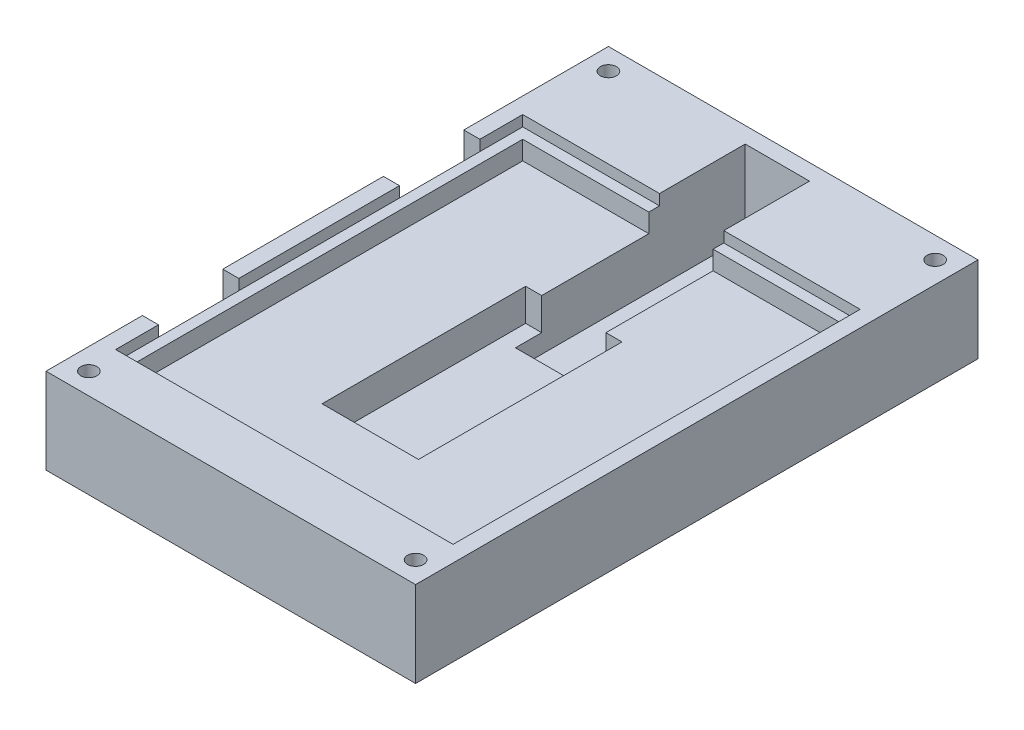
from build123d import *

# Parameters (mm, degrees)
SKETCH1_W           = 69
SKETCH1_H           = 105
BOSS_EXTRUDE1_DEPTH = 16
SKETCH2_W           = 63
SKETCH2_H           = 76
CUT_EXTRUDE1_DEPTH  = 2
SKETCH3_W           = 59
SKETCH3_H           = 72
CUT_EXTRUDE2_DEPTH  = 3.5
SKETCH4_W           = 18
SKETCH4_H           = 38
CUT_EXTRUDE3_DEPTH  = 6
SKETCH5_W           = 12
SKETCH5_H           = 31.473581166
CUT_EXTRUDE4_DEPTH  = 9.5
SKETCH6_W           = 12
SKETCH6_H           = 18
CUT_EXTRUDE5_DEPTH  = 15
SKETCH7_R           = 1.5
CUT_EXTRUDE6_DEPTH  = 10
CUT_EXTRUDE7_DEPTH  = 10
SKETCH13_W          = 3
SKETCH13_H          = 15
CUT_EXTRUDE8_DEPTH  = 17


with BuildPart() as part:
    # Sketch1 → Boss-Extrude1 (new body)
    with BuildSketch(Plane(origin=(0, 0, 0), x_dir=(1, 0, 0), z_dir=(0, 1, 0))):
        with Locations((34.5, 52.5)):
            Rectangle(SKETCH1_W, SKETCH1_H)
    extrude(amount=BOSS_EXTRUDE1_DEPTH)

    # Sketch2 → Cut-Extrude1 (cut)
    with BuildSketch(Plane(origin=(0, 16, 0), x_dir=(1, 0, 0), z_dir=(0, 1, 0))):
        with Locations((34.5, 48)):
            Rectangle(SKETCH2_W, SKETCH2_H)
    extrude(amount=-CUT_EXTRUDE1_DEPTH, mode=Mode.SUBTRACT)

    # Sketch3 → Cut-Extrude2 (cut)
    with BuildSketch(Plane(origin=(0, 14, 0), x_dir=(1, 0, 0), z_dir=(0, 1, 0))):
        with Locations((34.5, 48)):
            Rectangle(SKETCH3_W, SKETCH3_H)
    extrude(amount=-CUT_EXTRUDE2_DEPTH, mode=Mode.SUBTRACT)

    # Sketch4 → Cut-Extrude3 (cut)
    with BuildSketch(Plane(origin=(0, 10.5, 0), x_dir=(1, 0, 0), z_dir=(0, 1, 0))):
        with Locations((34.54, 45)):
            Rectangle(SKETCH4_W, SKETCH4_H)
    extrude(amount=-CUT_EXTRUDE3_DEPTH, mode=Mode.SUBTRACT)

    # Sketch5 → Cut-Extrude4 (cut)
    with BuildSketch(Plane(origin=(0, 10.5, 0), x_dir=(1, 0, 0), z_dir=(0, 1, 0))):
        with Locations((34.54, 74.837937429)):
            Rectangle(SKETCH5_W, SKETCH5_H)
    extrude(amount=-CUT_EXTRUDE4_DEPTH, mode=Mode.SUBTRACT)

    # Sketch6 → Cut-Extrude5 (cut)
    with BuildSketch(Plane(origin=(0, 16, 0), x_dir=(1, 0, 0), z_dir=(0, 1, 0))):
        with Locations((34.54, 93)):
            Rectangle(SKETCH6_W, SKETCH6_H)
    extrude(amount=-CUT_EXTRUDE5_DEPTH, mode=Mode.SUBTRACT)

    # Sketch7 → Cut-Extrude6 (cut)
    with BuildSketch(Plane(origin=(0, 16, 0), x_dir=(1, 0, 0), z_dir=(0, 1, 0))):
        with Locations((4, 4)):
            Circle(SKETCH7_R)
        with Locations((65, 4)):
            Circle(SKETCH7_R)
        with Locations((65, 101)):
            Circle(SKETCH7_R)
        with Locations((4, 101)):
            Circle(SKETCH7_R)
    extrude(amount=-CUT_EXTRUDE6_DEPTH, mode=Mode.SUBTRACT)

    # Sketch10 → Cut-Extrude7 (cut)
    with BuildSketch(Plane.ZY):
        Polygon((-90, 9.732050808), (-91.5, 8.866025404), (-91.5, 7.133974596), (-90, 6.267949192), (-88.5, 7.133974596), (-88.5, 8.866025404), align=None)
        Polygon((-52.5, 9.732050808), (-54, 8.866025404), (-54, 7.133974596), (-52.5, 6.267949192), (-51, 7.133974596), (-51, 8.866025404), align=None)
        Polygon((-15, 9.732050808), (-16.5, 8.866025404), (-16.5, 7.133974596), (-15, 6.267949192), (-13.5, 7.133974596), (-13.5, 8.866025404), align=None)
    extrude(amount=-CUT_EXTRUDE7_DEPTH, mode=Mode.SUBTRACT)

    # Sketch13 → Cut-Extrude8 (cut, through all)
    with BuildSketch(Plane(origin=(0, 16, 0), x_dir=(1, 0, 0), z_dir=(0, 1, 0))):
        with Locations((1.5, 70.5)):
            Rectangle(SKETCH13_W, SKETCH13_H)
        with Locations((1.5, 25.5)):
            Rectangle(SKETCH13_W, SKETCH13_H)
    extrude(amount=-CUT_EXTRUDE8_DEPTH, mode=Mode.SUBTRACT)


solid = part.part
